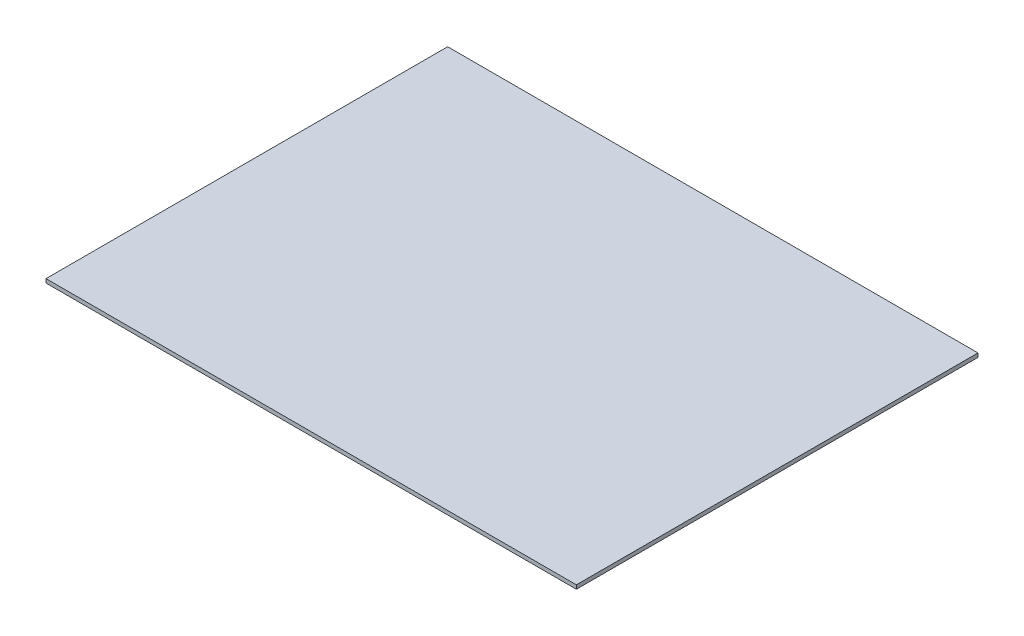
from build123d import *

# Parameters (mm, degrees)
SKETCH1_W           = 412
SKETCH1_H           = 312
BOSS_EXTRUDE1_DEPTH = 3


with BuildPart() as part:
    # Sketch1 → Boss-Extrude1 (new body)
    with BuildSketch(Plane(origin=(0, 0, 0), x_dir=(1, 0, 0), z_dir=(0, 1, 0))):
        with Locations((159.988248822, 4.757124999)):
            Rectangle(SKETCH1_W, SKETCH1_H)
    extrude(amount=BOSS_EXTRUDE1_DEPTH)


solid = part.part
